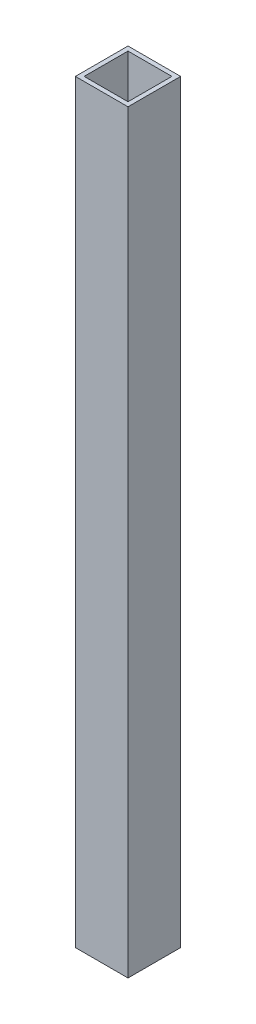
from build123d import *

# Parameters (mm, degrees)
SKETCH1_W           = 38.1
SKETCH1_H           = 38.1
SKETCH1_W_2         = 31.75
SKETCH1_H_2         = 31.75
BOSS_EXTRUDE1_DEPTH = 546.1


with BuildPart() as part:
    # Sketch1 → Boss-Extrude1 (new body)
    with BuildSketch(Plane(origin=(0, 0, 0), x_dir=(1, 0, 0), z_dir=(0, 1, 0))):
        with Locations((19.05, 19.05)):
            Rectangle(SKETCH1_W, SKETCH1_H)
        with Locations((19.05, 19.05)):
            Rectangle(SKETCH1_W_2, SKETCH1_H_2, mode=Mode.SUBTRACT)
    extrude(amount=BOSS_EXTRUDE1_DEPTH)


solid = part.part
